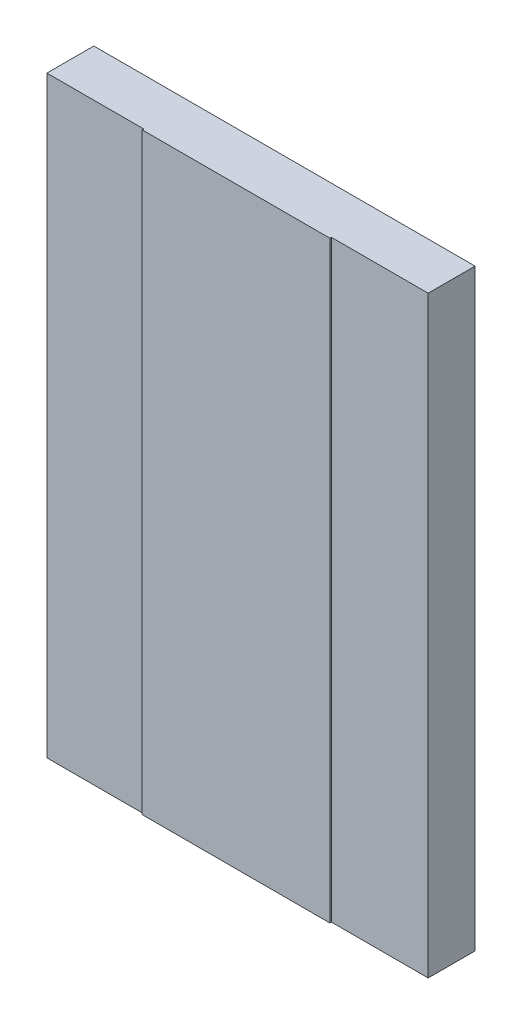
from build123d import *

# Parameters (mm, degrees)
SKETCH1_W           = 100.0125
SKETCH1_H           = 155.575
BOSS_EXTRUDE1_DEPTH = 6.35
CUT_EXTRUDE1_REACH  = 157.575
SKETCH4_W           = 25.4
SKETCH4_H           = 0.396875


with BuildPart() as part:
    # Sketch1 → Boss-Extrude1 (new body, symmetric)
    with BuildSketch(Plane.XY):
        Rectangle(SKETCH1_W, SKETCH1_H)
    extrude(amount=BOSS_EXTRUDE1_DEPTH, both=True)

    # Sketch4 → Cut-Extrude1 (cut, up to next)
    with BuildSketch(Plane(origin=(0, 77.7875, 0), x_dir=(1, 0, 0), z_dir=(0, 1, 0)), mode=Mode.PRIVATE) as cut_extrude1_sk1:
        with Locations((-37.30625, -6.1515625)):
            Rectangle(SKETCH4_W, SKETCH4_H)
    cut_extrude1_tool1 = extrude(cut_extrude1_sk1.sketch, amount=-CUT_EXTRUDE1_REACH, mode=Mode.PRIVATE) & part.part
    add(cut_extrude1_tool1.solids().sort_by_distance((-37.30625, 77.7875, 6.151562))[0], mode=Mode.SUBTRACT)
    # Sketch4 → Cut-Extrude1 (cut, up to next)
    with BuildSketch(Plane(origin=(0, 77.7875, 0), x_dir=(1, 0, 0), z_dir=(0, 1, 0)), mode=Mode.PRIVATE) as cut_extrude1_sk2:
        with Locations((37.30625, -6.1515625)):
            Rectangle(SKETCH4_W, SKETCH4_H)
    cut_extrude1_tool2 = extrude(cut_extrude1_sk2.sketch, amount=-CUT_EXTRUDE1_REACH, mode=Mode.PRIVATE) & part.part
    add(cut_extrude1_tool2.solids().sort_by_distance((37.30625, 77.7875, 6.151563))[0], mode=Mode.SUBTRACT)


solid = part.part
